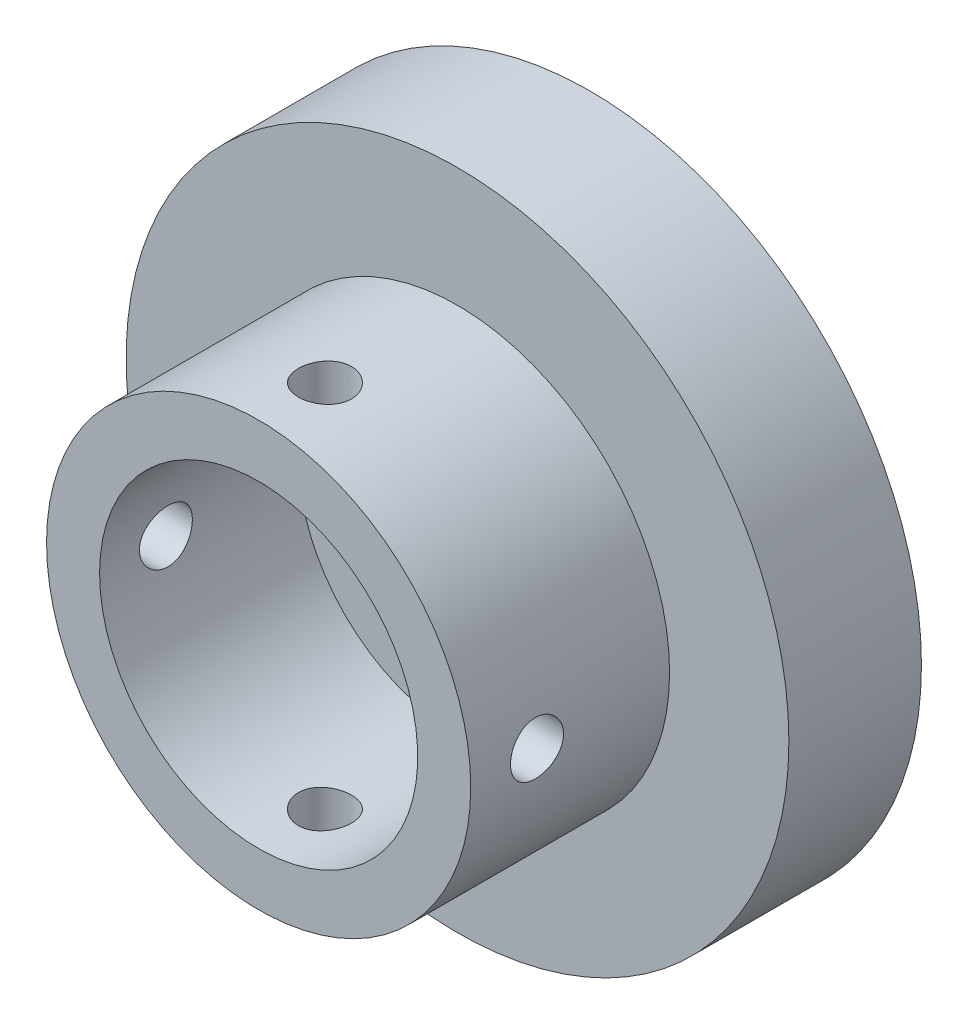
from build123d import *

# Parameters (mm, degrees)
SKIZZE1_R                            = 12.5
AUFSATZ_LINEAR_AUSTRAGEN1_DEPTH      = 40
SCHNITT_LINEAR_START                 = 30
SKIZZE4_R                            = 15
SKIZZE4_R_2                          = 12
SCHNITT_LINEAR_AUSTRAGEN1_DEPTH      = 20
SKIZZE5_R                            = 1.1
SCHNITT_LINEAR_AUSTRAGEN2_DEPTH      = 20
SKIZZE6_R                            = 1
SCHNITT_LINEAR_AUSTRAGEN3_DEPTH      = 10
SCHNITT_LINEAR_START_2               = 12.5
SKIZZE8_W                            = 25
SKIZZE8_H                            = 25
SCHNITT_LINEAR_AUSTRAGEN4_DEPTH      = 28.5
SKIZZE9_R                            = 1
SCHNITT_LINEAR_AUSTRAGEN5_DEPTH      = 13.5
SCHNITT_LINEAR_AUSTRAGEN5_DEPTH_BACK = 13.5
SKIZZE10_R                           = 1
SCHNITT_LINEAR_AUSTRAGEN6_DEPTH      = 13.5
SCHNITT_LINEAR_AUSTRAGEN6_DEPTH_BACK = 13.5


with BuildPart() as part:
    # Skizze1 → Aufsatz-Linear austragen1 (new body)
    with BuildSketch(Plane.XY):
        Circle(SKIZZE1_R)
    extrude(amount=AUFSATZ_LINEAR_AUSTRAGEN1_DEPTH)

    # Skizze2 → Schnitt-Rotation3 (revolve, cut)
    with BuildSketch(Plane(origin=(0, 0, 0), x_dir=(0, 0, -1), z_dir=(1, 0, 0))):
        Polygon((-35, -12.5), (-35, -8), (-5, -8), (-5, -12.5), (-33.974333956, -17.5), align=None)
    revolve(axis=Axis((0, 0, 40), (0, 0, -1)), mode=Mode.SUBTRACT)

    # Skizze4 → Schnitt-Linear austragen1 (cut)
    with BuildSketch(Plane.XY.offset(SCHNITT_LINEAR_START)):
        Circle(SKIZZE4_R)
        Circle(SKIZZE4_R_2, mode=Mode.SUBTRACT)
    extrude(amount=SCHNITT_LINEAR_AUSTRAGEN1_DEPTH, mode=Mode.SUBTRACT)

    # Skizze5 → Schnitt-Linear austragen2 (cut)
    with BuildSketch(Plane.XY.offset(40)):
        with Locations((-5.457266806, 6.503717322)):
            Circle(SKIZZE5_R)
        with Locations((6.503717322, 5.457266806)):
            Circle(SKIZZE5_R)
        with Locations((5.457266806, -6.503717322)):
            Circle(SKIZZE5_R)
        with Locations((-6.503717322, -5.457266806)):
            Circle(SKIZZE5_R)
    extrude(amount=-SCHNITT_LINEAR_AUSTRAGEN2_DEPTH, mode=Mode.SUBTRACT)

    # Skizze6 → Schnitt-Linear austragen3 (cut)
    with BuildSketch(Plane(origin=(0, 0, 0), x_dir=(-1, 0, 0), z_dir=(0, 0, -1))):
        with Locations((-2.25, 0)):
            Circle(SKIZZE6_R)
        with Locations((0, 2.25)):
            Circle(SKIZZE6_R)
        with Locations((2.25, 0)):
            Circle(SKIZZE6_R)
        with Locations((0, -2.25)):
            Circle(SKIZZE6_R)
    extrude(amount=-SCHNITT_LINEAR_AUSTRAGEN3_DEPTH, mode=Mode.SUBTRACT)

    # Skizze7 → Schnitt-Rotation4 (revolve, cut)
    with BuildSketch(Plane(origin=(0, 0, 0), x_dir=(0, 0, -1), z_dir=(1, 0, 0))):
        Polygon((-5.069914244, 0), (-35.074978214, 0), (-40, 0), (-42.313201415, 0), (-42.313201415, -6), (-40, -6), (-35, -6), (-5, -6), align=None)
    revolve(axis=Axis((0, 0, 40), (0, 0, -1)), mode=Mode.SUBTRACT)

    # Skizze8 → Schnitt-Linear austragen4 (cut, through all)
    with BuildSketch(Plane.XY.offset(SCHNITT_LINEAR_START_2)):
        Rectangle(SKIZZE8_W, SKIZZE8_H)
    extrude(amount=SCHNITT_LINEAR_AUSTRAGEN4_DEPTH, mode=Mode.SUBTRACT)

    # Skizze9 → Schnitt-Linear austragen5 (cut, two sides)
    with BuildSketch(Plane(origin=(0, 0, 0), x_dir=(0, 0, -1), z_dir=(1, 0, 0))) as schnitt_linear_austragen5_sk:
        with Locations((-10, 0)):
            Circle(SKIZZE9_R)
    extrude(amount=SCHNITT_LINEAR_AUSTRAGEN5_DEPTH, mode=Mode.SUBTRACT)
    extrude(schnitt_linear_austragen5_sk.sketch, amount=-SCHNITT_LINEAR_AUSTRAGEN5_DEPTH_BACK, mode=Mode.SUBTRACT)

    # Skizze10 → Schnitt-Linear austragen6 (cut, two sides)
    with BuildSketch(Plane(origin=(0, 0, 0), x_dir=(1, 0, 0), z_dir=(0, 1, 0))) as schnitt_linear_austragen6_sk:
        with Locations((0, -10)):
            Circle(SKIZZE10_R)
    extrude(amount=SCHNITT_LINEAR_AUSTRAGEN6_DEPTH, mode=Mode.SUBTRACT)
    extrude(schnitt_linear_austragen6_sk.sketch, amount=-SCHNITT_LINEAR_AUSTRAGEN6_DEPTH_BACK, mode=Mode.SUBTRACT)


solid = part.part
